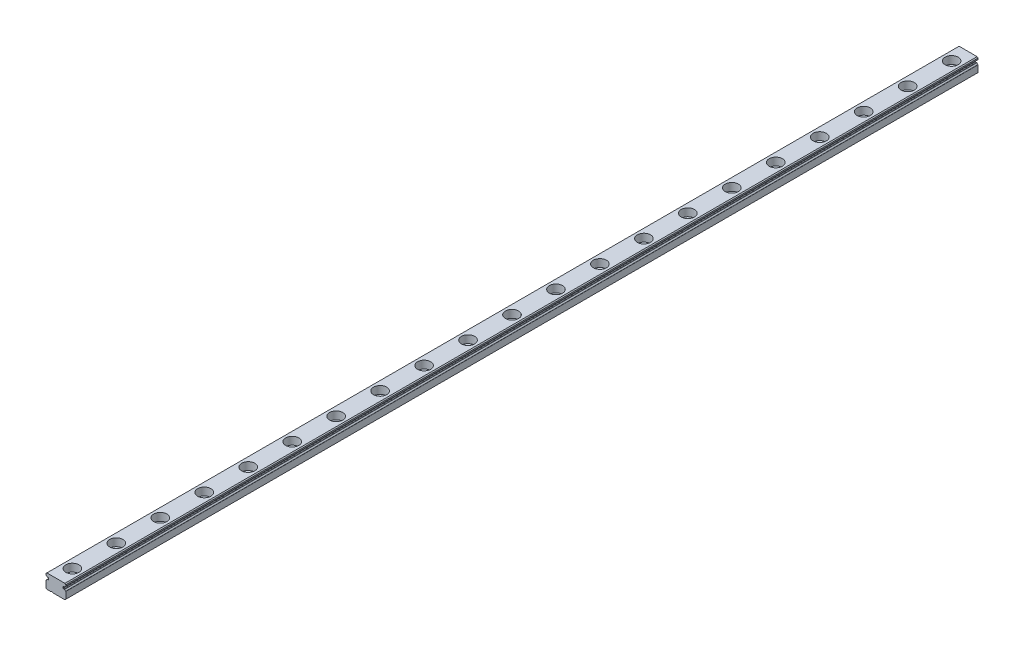
from build123d import *

# Parameters (mm, degrees)
BOSS_EXTRUDE1_DEPTH = 207.5
SKETCH3_R           = 1.75
CUT_EXTRUDE2_DEPTH  = 208.650547796
SKETCH3_3_R         = 3
SKETCH3_3_R_2       = 1.75
CUT_EXTRUDE3_DEPTH  = 3.5


with BuildPart() as part:
    # Sketch1 → Boss-Extrude1 (new, symmetric)
    with BuildSketch(Plane.XY):
        with BuildLine():
            Line((-1.4, -6.5), (4.1, -6.5))
            Line((4.1, -6.5), (4.5, -6.1))
            Line((4.5, -6.1), (4.5, -3.058303524))
            ThreePointArc((4.5, -3.058303524), (4.475108648, -2.975551932), (4.408695652, -2.920264326))
            ThreePointArc((4.408695652, -2.920264326), (4.141262777, -2.752376093), (3.939510483, -2.509471145))
            ThreePointArc((3.939510483, -2.509471145), (3.890337026, -2.458942579), (3.823510417, -2.436462162))
            Line((3.823510417, -2.436462162), (3.482568852, -2.40663364))
            ThreePointArc((3.482568852, -2.40663364), (3.352544533, -2.342512742), (3.3, -2.207394701))
            Line((3.3, -2.207394701), (3.3, -1.792605299))
            ThreePointArc((3.3, -1.792605299), (3.352544533, -1.657487258), (3.482568852, -1.59336636))
            Line((3.482568852, -1.59336636), (3.823514163, -1.56353751))
            ThreePointArc((3.823514163, -1.56353751), (3.890340367, -1.541057348), (3.939513741, -1.490529352))
            ThreePointArc((3.939513741, -1.490529352), (4.141265182, -1.247627801), (4.408695652, -1.079741674))
            ThreePointArc((4.408695652, -1.079741674), (4.475108648, -1.024454068), (4.5, -0.941702476))
            Line((4.5, -0.941702476), (4.5, -0.4))
            Line((4.5, -0.4), (4.1, 0))
            Line((4.1, 0), (-4.1, 0))
            Line((-4.1, 0), (-4.5, -0.4))
            Line((-4.5, -0.4), (-4.5, -0.941702476))
            ThreePointArc((-4.5, -0.941702476), (-4.475108648, -1.024454068), (-4.408695652, -1.079741674))
            ThreePointArc((-4.408695652, -1.079741674), (-4.141265182, -1.247627801), (-3.939513741, -1.490529352))
            ThreePointArc((-3.939513741, -1.490529352), (-3.890340367, -1.541057348), (-3.823514163, -1.56353751))
            Line((-3.823514163, -1.56353751), (-3.482568852, -1.59336636))
            ThreePointArc((-3.482568852, -1.59336636), (-3.352544533, -1.657487258), (-3.3, -1.792605299))
            Line((-3.3, -1.792605299), (-3.3, -2.207394701))
            ThreePointArc((-3.3, -2.207394701), (-3.352544533, -2.342512742), (-3.482568852, -2.40663364))
            Line((-3.482568852, -2.40663364), (-3.823510417, -2.436462162))
            ThreePointArc((-3.823510417, -2.436462162), (-3.890337026, -2.458942579), (-3.939510483, -2.509471145))
            ThreePointArc((-3.939510483, -2.509471145), (-4.141262777, -2.752376093), (-4.408695652, -2.920264326))
            ThreePointArc((-4.408695652, -2.920264326), (-4.475108648, -2.975551932), (-4.5, -3.058303524))
            Line((-4.5, -3.058303524), (-4.5, -6.1))
            Line((-4.5, -6.1), (-4.1, -6.5))
            Line((-4.1, -6.5), (-2.2, -6.5))
            ThreePointArc((-2.2, -6.5), (-1.8, -6.3), (-1.4, -6.5))
        make_face()
    extrude(amount=BOSS_EXTRUDE1_DEPTH, both=True)

    # Sketch3 → Cut-Extrude2 (cut, through all)
    with BuildSketch(Plane(origin=(0, 0, 0), x_dir=(1, 0, 0), z_dir=(0, 1, 0))):
        with Locations((0, -200)):
            Circle(SKETCH3_R)
    cut_extrude2 = extrude(amount=-CUT_EXTRUDE2_DEPTH, mode=Mode.SUBTRACT)

    # Sketch3_3 → Cut-Extrude3 (cut)
    with BuildSketch(Plane(origin=(0, 0, 0), x_dir=(1, 0, 0), z_dir=(0, 1, 0))):
        with Locations((0, -200)):
            Circle(SKETCH3_3_R)
        with Locations((0, -200)):
            Circle(SKETCH3_3_R_2, mode=Mode.SUBTRACT)
    cut_extrude3 = extrude(amount=-CUT_EXTRUDE3_DEPTH, mode=Mode.SUBTRACT)

    # Sketch-Pattern1: Cut-Extrude2, Cut-Extrude3 at 29 more places
    with Locations((0, 0, -20), (0, 0, -40), (0, 0, -60), (0, 0, -80), (0, 0, -100), (0, 0, -120), (0, 0, -140), (0, 0, -160), (0, 0, -180), (0, 0, -200), (0, 0, -220), (0, 0, -240), (0, 0, -260), (0, 0, -280), (0, 0, -300), (0, 0, -320), (0, 0, -340), (0, 0, -360), (0, 0, -380), (0, 0, -400), (0, 0, -420), (0, 0, -440), (0, 0, -460), (0, 0, -480), (0, 0, -500), (0, 0, -520), (0, 0, -540), (0, 0, -560), (0, 0, -580)):
        add(cut_extrude2, mode=Mode.SUBTRACT)
        add(cut_extrude3, mode=Mode.SUBTRACT)


solid = part.part
